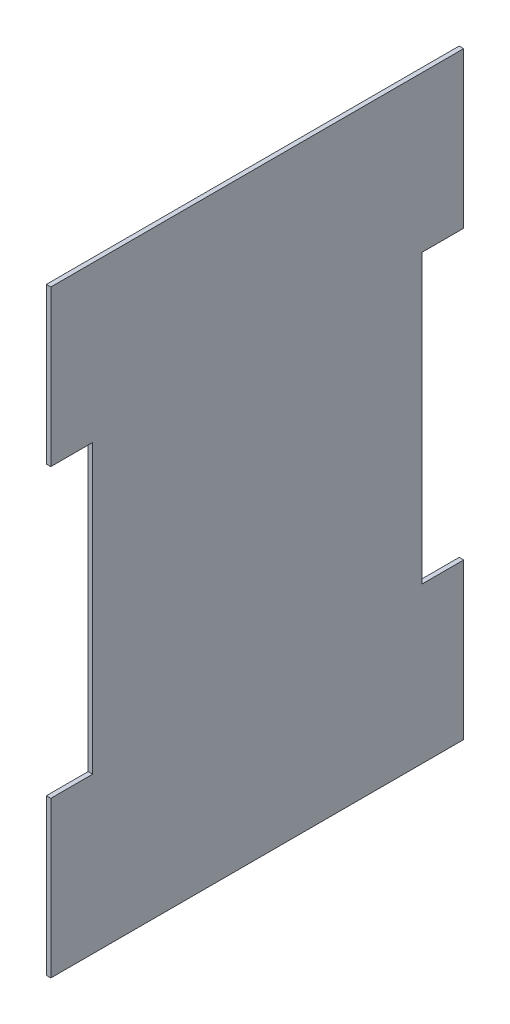
from build123d import *

# Parameters (mm, degrees)
SKETCH1_W           = 276
SKETCH1_H           = 400
BOSS_EXTRUDE1_DEPTH = 3
SKETCH2_W           = 28
SKETCH2_H           = 192
CUT_EXTRUDE1_DEPTH  = 25


with BuildPart() as part:
    # Sketch1 → Boss-Extrude1 (new body)
    with BuildSketch(Plane(origin=(0, 0, 0), x_dir=(0, 0, -1), z_dir=(1, 0, 0))):
        with Locations((-123.692307692, -9.461538462)):
            Rectangle(SKETCH1_W, SKETCH1_H)
    extrude(amount=BOSS_EXTRUDE1_DEPTH)

    # Sketch2 → Cut-Extrude1 (cut)
    with BuildSketch(Plane(origin=(0, 0, 0), x_dir=(0, 0, -1), z_dir=(1, 0, 0))):
        with Locations((0.307692308, -9.461538462)):
            Rectangle(SKETCH2_W, SKETCH2_H)
        with Locations((-247.692307692, -9.461538462)):
            Rectangle(SKETCH2_W, SKETCH2_H)
    extrude(amount=CUT_EXTRUDE1_DEPTH, mode=Mode.SUBTRACT)


solid = part.part
